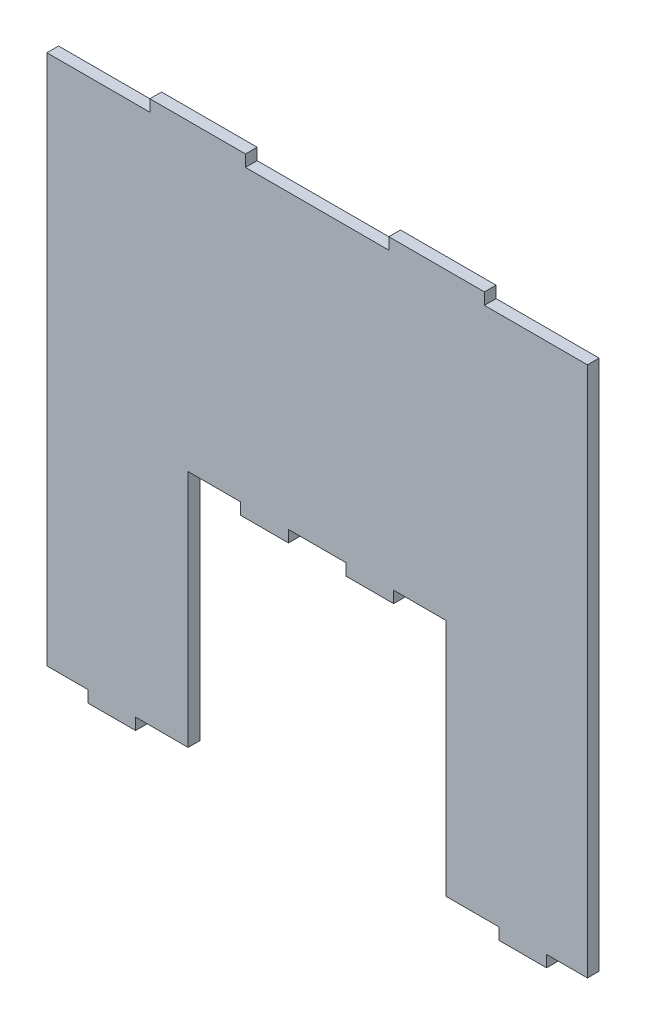
from build123d import *

# Parameters (mm, degrees)
SALIENTE_EXTRUIR1_DEPTH = 2.44


with BuildPart() as part:
    # Croquis1 → Saliente-Extruir1 (new body)
    with BuildSketch(Plane.XY):
        Polygon((-56.56, -55.56), (-48, -55.56), (-48, -58), (-38, -58), (-38, -55.56), (-27, -55.56), (-27, -5.56), (-16, -5.56), (-16, -8), (-6, -8), (-6, -5.56), (6, -5.56), (6, -8), (16, -8), (16, -5.56), (27, -5.56), (27, -55.56), (38, -55.56), (38, -58), (48, -58), (48, -55.56), (56.56, -55.56), (56.56, 55.56), (35, 55.56), (35, 58), (15, 58), (15, 55.56), (-15, 55.56), (-15, 58), (-35, 58), (-35, 55.56), (-56.56, 55.56), align=None)
    extrude(amount=SALIENTE_EXTRUIR1_DEPTH)


solid = part.part
